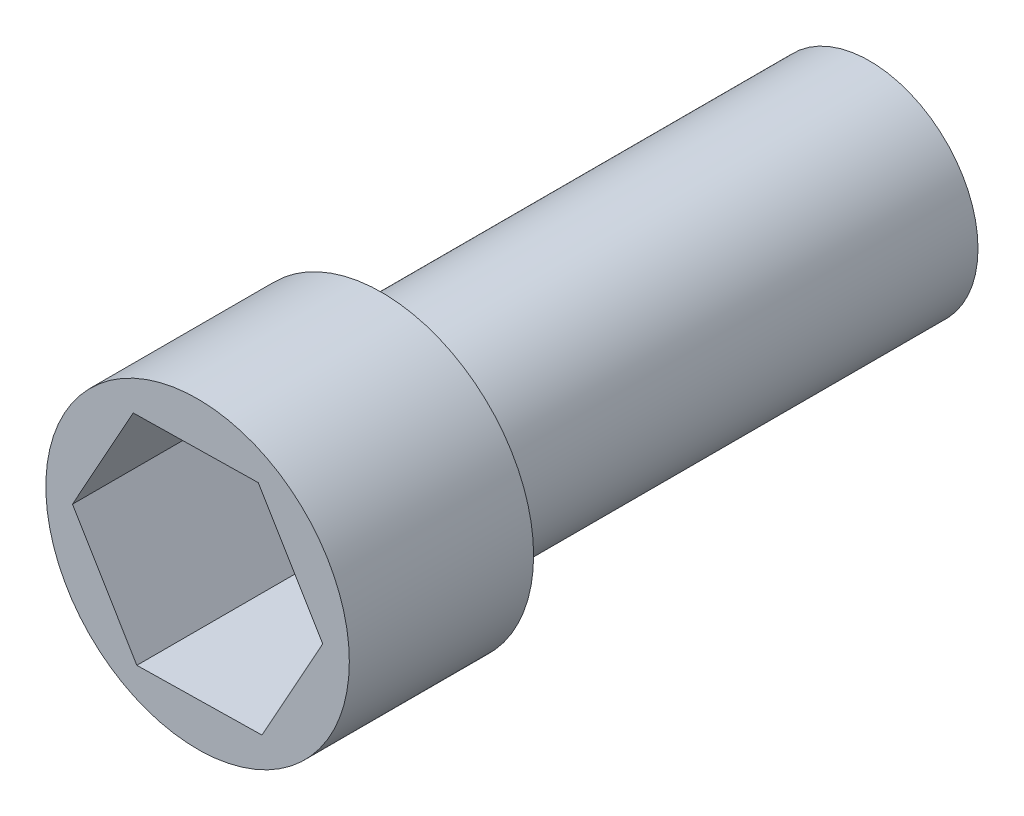
from build123d import *

# Parameters (mm, degrees)
SKETCH1_R           = 14
BOSS_EXTRUDE1_DEPTH = 17
SKETCH2_R           = 10
BOSS_EXTRUDE2_DEPTH = 45
CUT_EXTRUDE1_DEPTH  = 16


with BuildPart() as part:
    # Sketch1 → Boss-Extrude1 (new body)
    with BuildSketch(Plane.XY):
        Circle(SKETCH1_R)
    extrude(amount=-BOSS_EXTRUDE1_DEPTH)

    # Sketch2 → Boss-Extrude2 (add)
    with BuildSketch(Plane(origin=(0, 0, -17), x_dir=(-1, 0, 0), z_dir=(0, 0, -1))):
        Circle(SKETCH2_R)
    extrude(amount=BOSS_EXTRUDE2_DEPTH)

    # Sketch3 → Cut-Extrude1 (cut)
    with BuildSketch(Plane.XY):
        Polygon((5.601358059, 10.097431417), (-5.943953091, 9.899634083), (-11.54531115, -0.197797334), (-5.601358059, -10.097431417), (5.943953091, -9.899634083), (11.54531115, 0.197797334), align=None)
    extrude(amount=-CUT_EXTRUDE1_DEPTH, mode=Mode.SUBTRACT)


solid = part.part
